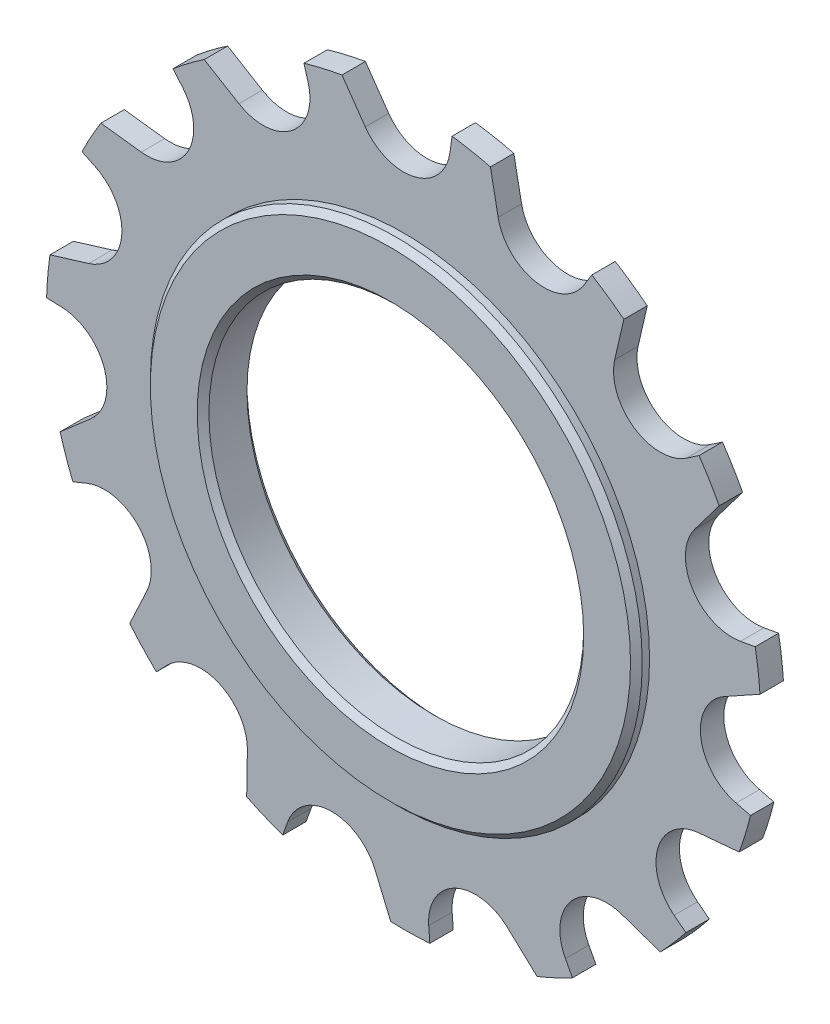
from build123d import *

# Parameters (mm, degrees)
ESQUISSE1_R                  = 30.5
EXTRUSION1_DEPTH             = 1
ENL_V_MAT_EXTRU_1_DEPTH      = 2
R_P_TITION_CIRCULAIRE1_COUNT = 15
ESQUISSE3_R                  = 21
EXTRUSION2_DEPTH             = 2.125
ESQUISSE4_R                  = 16
ENL_V_MAT_EXTRU_2_DEPTH      = 3.125
ENL_V_MAT_EXTRU_2_DEPTH_BACK = 3.125
CHANFREIN1_SIZE              = 0.5


with BuildPart() as part:
    # Esquisse1 → Extrusion1 (new body, symmetric)
    with BuildSketch(Plane.XY):
        Circle(ESQUISSE1_R)
    extrude(amount=EXTRUSION1_DEPTH, both=True)

    # Esquisse2 → Enlèv. mat.-Extru.1 (cut, symmetric)
    with BuildSketch(Plane.XY):
        with BuildLine():
            Line((-5.262955088, 30.042491637), (-3.276608177, 27.205694255))
            ThreePointArc((-3.276608177, 27.205694255), (0.940808513, 25.612214082), (3.963058372, 28.957627119))
            Line((3.963058372, 28.957627119), (4.13559322, 30.218320084))
            ThreePointArc((4.13559322, 30.218320084), (-0.570495492, 30.49466404), (-5.262955088, 30.042491637))
        make_face()
    enl_v_mat_extru_1 = extrude(amount=ENL_V_MAT_EXTRU_1_DEPTH, both=True, mode=Mode.SUBTRACT)

    # Répétition circulaire1: Enlèv. mat.-Extru.1 ×15 about axis
    r_p_tition_circulaire1_axis = Axis((0, 0, 0), (0, 0, 1))
    for i in range(1, R_P_TITION_CIRCULAIRE1_COUNT):
        add(enl_v_mat_extru_1.rotate(r_p_tition_circulaire1_axis, i * 360 / R_P_TITION_CIRCULAIRE1_COUNT), mode=Mode.SUBTRACT)

    # Esquisse3 → Extrusion2 (add, symmetric)
    with BuildSketch(Plane.XY):
        Circle(ESQUISSE3_R)
    extrude(amount=EXTRUSION2_DEPTH, both=True)

    # Esquisse4 → Enlèv. mat.-Extru.2 (cut, two sides)
    with BuildSketch(Plane.XY) as enl_v_mat_extru_2_sk:
        Circle(ESQUISSE4_R)
    extrude(amount=ENL_V_MAT_EXTRU_2_DEPTH, mode=Mode.SUBTRACT)
    extrude(enl_v_mat_extru_2_sk.sketch, amount=-ENL_V_MAT_EXTRU_2_DEPTH_BACK, mode=Mode.SUBTRACT)

    # Chanfrein1
    chanfrein1_edges = [part.edges().sort_by_distance(p)[0] for p in [
        (-21, 0, -2.125),
        (-21, 0, 2.125),
        (-16, 0, -2.125),
        (-16, 0, 2.125),
    ]]
    chamfer(chanfrein1_edges, length=CHANFREIN1_SIZE)


solid = part.part
